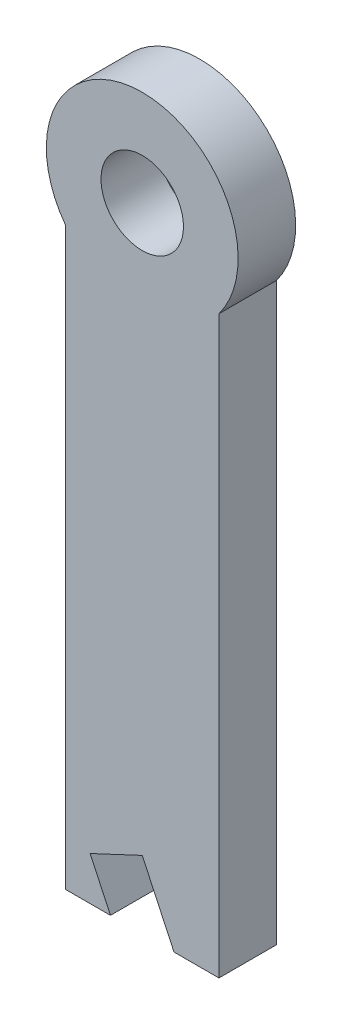
from build123d import *

# Parameters (mm, degrees)
SKETCH1_R           = 2.15
BOSS_EXTRUDE1_DEPTH = 3


with BuildPart() as part:
    # Sketch1 → Boss-Extrude1 (new body)
    with BuildSketch(Plane.XY):
        with BuildLine():
            Line((4, -33), (4, -3))
            ThreePointArc((4, -3), (0, 5), (-4, -3))
            Line((-4, -3), (-4, -33))
            Line((-4, -33), (-1.656379773, -33))
            Line((-1.656379773, -33), (-2.716768264, -30.736026447))
            Line((-2.716768264, -30.736026447), (0, -29.463560258))
            Line((0, -29.463560258), (1.656379773, -33))
            Line((1.656379773, -33), (4, -33))
        make_face()
        Circle(SKETCH1_R, mode=Mode.SUBTRACT)
    extrude(amount=BOSS_EXTRUDE1_DEPTH)


solid = part.part
